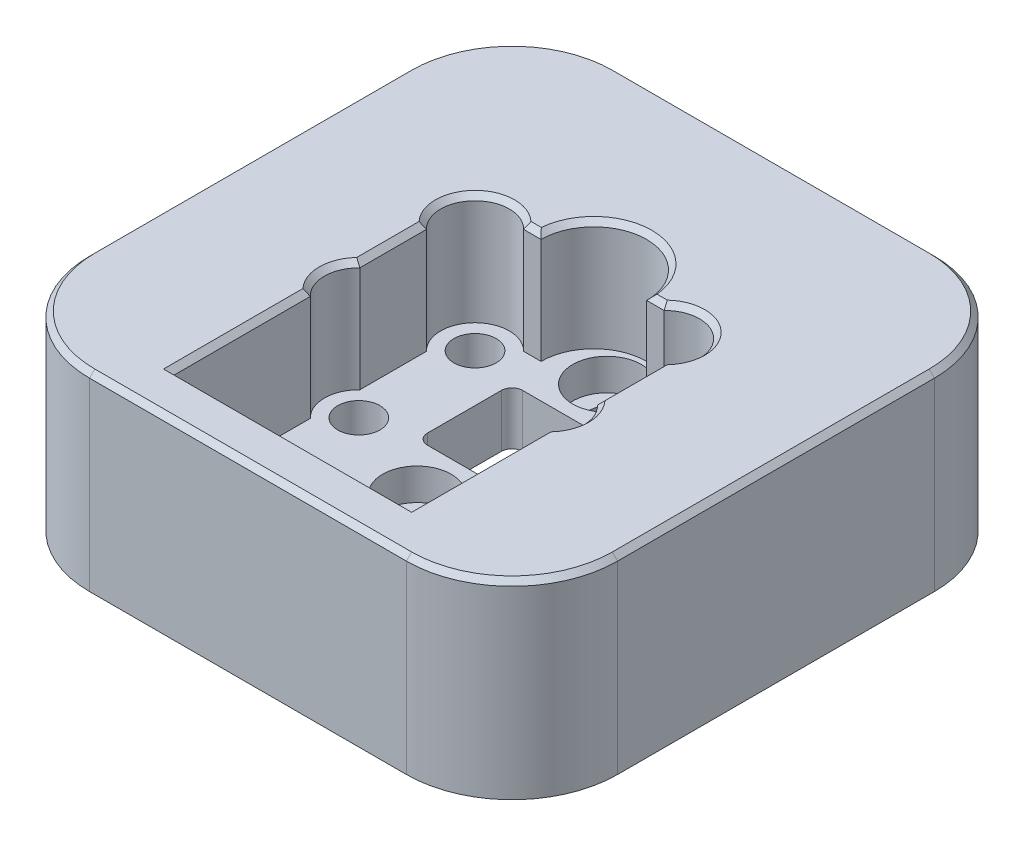
from build123d import *

# Parameters (mm, degrees)
SKETCH2_W                      = 50
SKETCH2_H                      = 50
BOSS_EXTRUDE1_DEPTH            = 10
SKETCH3_W                      = 9
SKETCH3_H                      = 9
CUT_EXTRUDE1_DEPTH             = 10
SKETCH4_R                      = 23.125
CUT_EXTRUDE2_DEPTH             = 2.5
F_4_0MM_DOWEL_HOLE1_D          = 4
FILLET1_R                      = 1
FILLET2_R                      = 10
CUT_EXTRUDE3_DEPTH             = 2.5
CBORE_FOR_M3_SHCS2_D           = 3.4
CBORE_FOR_M3_SHCS2_CBORE_D     = 6.5
CBORE_FOR_M3_SHCS2_CBORE_DEPTH = 3
SKETCH21_R                     = 3.25
CUT_EXTRUDE5_DEPTH             = 2.5
BOSS_EXTRUDE2_DEPTH            = 8
CHAMFER1_SIZE                  = 0.5


with BuildPart() as part:
    # Sketch2 → Boss-Extrude1 (new body)
    with BuildSketch(Plane(origin=(0, 0, 0), x_dir=(1, 0, 0), z_dir=(0, 1, 0))):
        Rectangle(SKETCH2_W, SKETCH2_H)
    extrude(amount=BOSS_EXTRUDE1_DEPTH)

    # Sketch3 → Cut-Extrude1 (cut)
    with BuildSketch(Plane(origin=(0, 10, 0), x_dir=(1, 0, 0), z_dir=(0, 1, 0))):
        Rectangle(SKETCH3_W, SKETCH3_H)
    extrude(amount=-CUT_EXTRUDE1_DEPTH, mode=Mode.SUBTRACT)

    # Sketch4 → Cut-Extrude2 (cut)
    with BuildSketch(Plane.XZ):
        Circle(SKETCH4_R)
    extrude(amount=-CUT_EXTRUDE2_DEPTH, mode=Mode.SUBTRACT)

    # Ø4.0mm Dowel Hole1 (through all)
    with Locations(Plane(origin=(0, 10, 0), x_dir=(1, 0, 0), z_dir=(0, 1, 0))):
        with Locations((-9, 5.5), (9, 5.5), (9, -5.5), (-9, -5.5)):
            Hole(F_4_0MM_DOWEL_HOLE1_D / 2)

    # Fillet1
    fillet1_edges = [part.edges().sort_by_distance(p)[0] for p in [
        (4.5, 6.25, -4.5),
        (-4.5, 6.25, -4.5),
        (-4.5, 6.25, 4.5),
        (4.5, 6.25, 4.5),
    ]]
    fillet(fillet1_edges, radius=FILLET1_R)

    # Fillet2
    fillet2_edges = [part.edges().sort_by_distance(p)[0] for p in [
        (-25, 5, -25),
        (25, 5, -25),
        (25, 5, 25),
        (-25, 5, 25),
    ]]
    fillet(fillet2_edges, radius=FILLET2_R)

    # Sketch17 → Cut-Extrude3 (cut)
    with BuildSketch(Plane(origin=(0, 10, 0), x_dir=(1, 0, 0), z_dir=(0, 1, 0))):
        with BuildLine():
            Line((5, 7.75), (11.25, 7.75))
            Line((11.25, 7.75), (11.25, -20.75))
            Line((11.25, -20.75), (-11.25, -20.75))
            Line((-11.25, -20.75), (-11.25, 7.75))
            Line((-11.25, 7.75), (-5, 7.75))
            ThreePointArc((-5, 7.75), (0, 12.75), (5, 7.75))
        make_face()
    extrude(amount=-CUT_EXTRUDE3_DEPTH, mode=Mode.SUBTRACT)

    # CBORE for M3 SHCS2 (through all)
    with Locations(Plane(origin=(0, 7.5, 0), x_dir=(1, 0, 0), z_dir=(0, 1, 0))):
        with Locations((0, -9), (0, 9)):
            CounterBoreHole(CBORE_FOR_M3_SHCS2_D / 2, CBORE_FOR_M3_SHCS2_CBORE_D / 2, CBORE_FOR_M3_SHCS2_CBORE_DEPTH)

    # Sketch21 → Cut-Extrude5 (cut)
    with BuildSketch(Plane(origin=(0, 10, 0), x_dir=(1, 0, 0), z_dir=(0, 1, 0))):
        with Locations((-9, 5.5)):
            Circle(SKETCH21_R)
        with Locations((9, 5.5)):
            Circle(SKETCH21_R)
        with Locations((9, -5.5)):
            Circle(SKETCH21_R)
        with Locations((-9, -5.5)):
            Circle(SKETCH21_R)
    extrude(amount=-CUT_EXTRUDE5_DEPTH, mode=Mode.SUBTRACT)

    # Sketch22 → Boss-Extrude2 (add)
    with BuildSketch(Plane(origin=(0, 10, 0), x_dir=(1, 0, 0), z_dir=(0, 1, 0))):
        with BuildLine():
            Line((-15, -25), (15, -25))
            ThreePointArc((15, -25), (22.071067812, -22.071067812), (25, -15))
            Line((25, -15), (25, 15))
            ThreePointArc((25, 15), (22.071067812, 22.071067812), (15, 25))
            Line((15, 25), (-15, 25))
            ThreePointArc((-15, 25), (-22.071067812, 22.071067812), (-25, 15))
            Line((-25, 15), (-25, -15))
            ThreePointArc((-25, -15), (-22.071067812, -22.071067812), (-15, -25))
        make_face()
        with BuildLine():
            Line((-11.25, 3.15479212), (-11.25, -3.15479212))
            ThreePointArc((-11.25, -3.15479212), (-12.25, -5.5), (-11.25, -7.84520788))
            Line((-11.25, -7.84520788), (-11.25, -20.75))
            Line((-11.25, -20.75), (11.25, -20.75))
            Line((11.25, -20.75), (11.25, -7.84520788))
            ThreePointArc((11.25, -7.84520788), (12.25, -5.5), (11.25, -3.15479212))
            Line((11.25, -3.15479212), (11.25, 3.15479212))
            ThreePointArc((11.25, 3.15479212), (11.298097039, 7.798097039), (6.65479212, 7.75))
            Line((6.65479212, 7.75), (5, 7.75))
            ThreePointArc((5, 7.75), (0, 12.75), (-5, 7.75))
            Line((-5, 7.75), (-6.65479212, 7.75))
            ThreePointArc((-6.65479212, 7.75), (-11.298097039, 7.798097039), (-11.25, 3.15479212))
        make_face(mode=Mode.SUBTRACT)
    extrude(amount=BOSS_EXTRUDE2_DEPTH)

    # Chamfer1
    chamfer1_edges = [part.edges().sort_by_distance(p)[0] for p in [
        (-22.071067812, 18, 22.071067812),
        (0, 18, 25),
        (22.071067812, 18, 22.071067812),
        (25, 18, 0),
        (22.071067812, 18, -22.071067812),
        (0, 18, -25),
        (-22.071067812, 18, -22.071067812),
        (-25, 18, 0),
        (-11.298097039, 18, -7.798097039),
        (-11.25, 18, 0),
        (-12.25, 18, 5.5),
        (-11.25, 18, 14.29760394),
        (0, 18, 20.75),
        (11.25, 18, 14.29760394),
        (12.25, 18, 5.5),
        (11.25, 18, 0),
        (11.298097039, 18, -7.798097039),
        (5.82739606, 18, -7.75),
        (0, 18, -12.75),
        (-5.82739606, 18, -7.75),
    ]]
    chamfer(chamfer1_edges, length=CHAMFER1_SIZE)


solid = part.part
